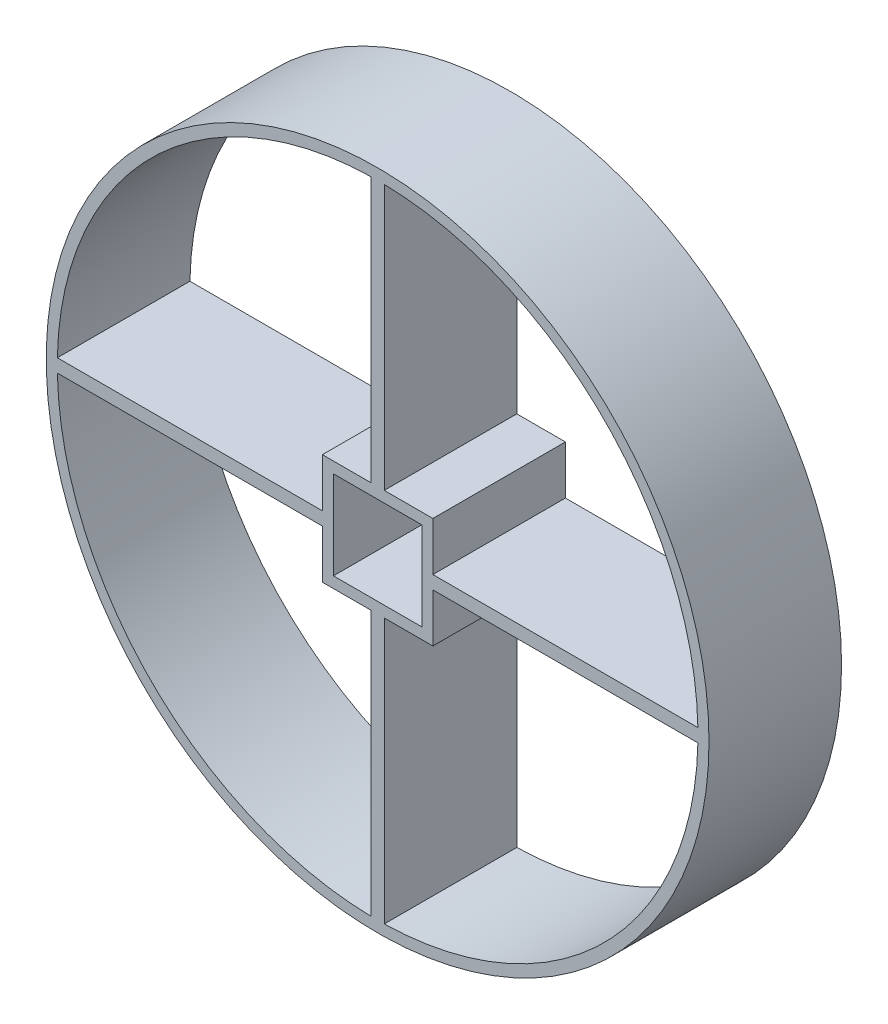
from build123d import *

# Parameters (mm, degrees)
SKETCH_1_R          = 30
EXTRUDE_2_DEPTH     = 6
SKETCH_6_W          = 8
SKETCH_6_H          = 8
CUT_EXTRUDE_2_DEPTH = 45.09081537


with BuildPart() as part:
    # 草图1 → 凸台-拉伸2 (new, symmetric)
    with BuildSketch(Plane.XY):
        Circle(SKETCH_1_R)
    extrude(amount=EXTRUDE_2_DEPTH, both=True)

    # 草图6 → 切除-拉伸2 (cut, through all)
    with BuildSketch(Plane.XY.offset(6)):
        with BuildLine():
            Line((-0.6, 28.993792439), (-0.6, 5))
            Line((-0.6, 5), (-5, 5))
            Line((-5, 5), (-5, 0.6))
            Line((-5, 0.6), (-28.993792439, 0.6))
            ThreePointArc((-28.993792439, 0.6), (-20.506096654, 20.506096654), (-0.6, 28.993792439))
        make_face()
        with BuildLine():
            Line((-28.993792439, -0.6), (-5, -0.6))
            Line((-5, -0.6), (-5, -5))
            Line((-5, -5), (-0.6, -5))
            Line((-0.6, -5), (-0.6, -28.993792439))
            ThreePointArc((-0.6, -28.993792439), (-20.506096654, -20.506096654), (-28.993792439, -0.6))
        make_face()
        with BuildLine():
            Line((0.6, 28.993792439), (0.6, 5))
            Line((0.6, 5), (5, 5))
            Line((5, 5), (5, 0.6))
            Line((5, 0.6), (28.993792439, 0.6))
            ThreePointArc((28.993792439, 0.6), (20.506096654, 20.506096654), (0.6, 28.993792439))
        make_face()
        with BuildLine():
            Line((5, -0.6), (28.993792439, -0.6))
            ThreePointArc((28.993792439, -0.6), (20.506096654, -20.506096654), (0.6, -28.993792439))
            Line((0.6, -28.993792439), (0.6, -5))
            Line((0.6, -5), (5, -5))
            Line((5, -5), (5, -0.6))
        make_face()
        Rectangle(SKETCH_6_W, SKETCH_6_H)
    extrude(amount=-CUT_EXTRUDE_2_DEPTH, mode=Mode.SUBTRACT)


solid = part.part
